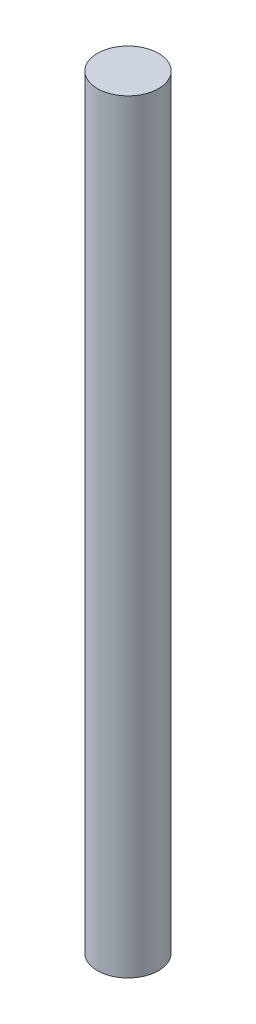
from build123d import *

# Parameters (mm, degrees)
SKETCH1_R           = 20
BOSS_EXTRUDE1_DEPTH = 500


with BuildPart() as part:
    # Sketch1 → Boss-Extrude1 (new body)
    with BuildSketch(Plane(origin=(0, 0, 0), x_dir=(1, 0, 0), z_dir=(0, 1, 0))):
        Circle(SKETCH1_R)
    extrude(amount=BOSS_EXTRUDE1_DEPTH)


solid = part.part
